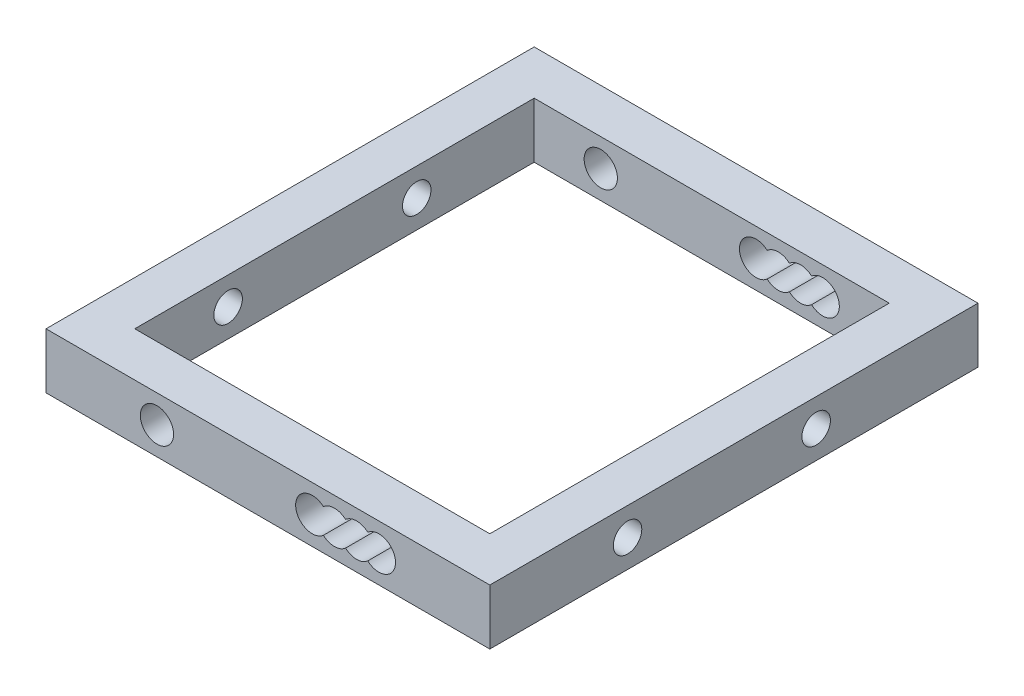
from build123d import *

# Parameters (mm, degrees)
ESBO_O1_W                = 32
ESBO_O1_H                = 5
ESBO_O1_R                = 1.5
RESSALTO_EXTRUS_O1_DEPTH = 4
ESBO_O3_W                = 4
ESBO_O3_H                = 5
RESSALTO_EXTRUS_O2_DEPTH = 44
PADR_O_LINEAR1_COUNT     = 2
PADR_O_LINEAR1_PITCH     = 40
ESBO_O4_R                = 1.285304246
CORTE_EXTRUS_O1_DEPTH    = 39


with BuildPart() as part:
    # Esboço1 → Ressalto-extrusão1 (new body)
    with BuildSketch(Plane.XY):
        Rectangle(ESBO_O1_W, ESBO_O1_H)
        with Locations((-10, 0)):
            Circle(ESBO_O1_R, mode=Mode.SUBTRACT)
        with BuildLine():
            ThreePointArc((5, 1.118033989), (2.5, 0), (5, -1.118033989))
            ThreePointArc((5, -1.118033989), (6, -1.5), (7, -1.118033989))
            ThreePointArc((7, -1.118033989), (8, -1.5), (9, -1.118033989))
            ThreePointArc((9, -1.118033989), (11.5, 0), (9, 1.118033989))
            ThreePointArc((9, 1.118033989), (8, 1.5), (7, 1.118033989))
            ThreePointArc((7, 1.118033989), (6, 1.5), (5, 1.118033989))
        make_face(mode=Mode.SUBTRACT)
    ressalto_extrus_o1 = extrude(amount=RESSALTO_EXTRUS_O1_DEPTH)

    # Esboço3 → Ressalto-extrusão2 (add)
    with BuildSketch(Plane.XY.offset(4)):
        with Locations((18, 0)):
            Rectangle(ESBO_O3_W, ESBO_O3_H)
    ressalto_extrus_o2 = extrude(amount=-RESSALTO_EXTRUS_O2_DEPTH)

    # Padrão linear1: Ressalto-extrusão1 ×2
    with Locations(*[(0, 0, -i * PADR_O_LINEAR1_PITCH) for i in range(1, PADR_O_LINEAR1_COUNT)]):
        add(ressalto_extrus_o1)

    # Espelhar1: Ressalto-extrusão2 across plane
    add(ressalto_extrus_o2.mirror(Plane(origin=(0, 0, 0), x_dir=(0, 0, 1), z_dir=(1, 0, 0))))

    # Esboço4 → Corte-extrusão1 (cut)
    with BuildSketch(Plane(origin=(20, 0, 0), x_dir=(0, 0, -1), z_dir=(1, 0, 0))):
        with Locations((8.412908062, 0)):
            Circle(ESBO_O4_R)
        with Locations((25.412908062, 0)):
            Circle(ESBO_O4_R)
    extrude(amount=-CORTE_EXTRUS_O1_DEPTH, mode=Mode.SUBTRACT)


solid = part.part
